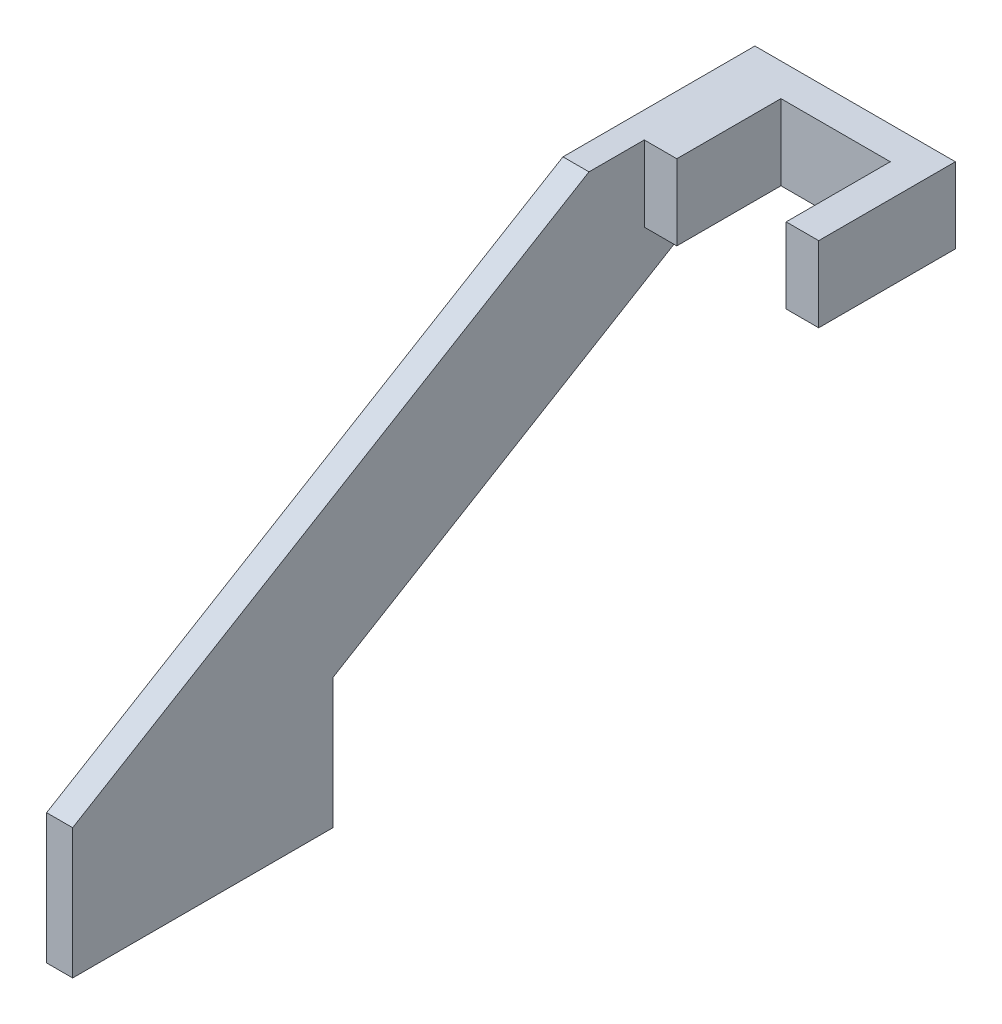
from build123d import *

# Parameters (mm, degrees)
BOSS_EXTRUDE1_DEPTH = 2.54
SKETCH2_W           = 3.175
SKETCH2_H           = 7.366
BOSS_EXTRUDE2_DEPTH = 3.175
SKETCH3_W           = 3.175
SKETCH3_H           = 7.366
BOSS_EXTRUDE4_DEPTH = 10.668
SKETCH4_W           = 13.335
SKETCH4_H           = 7.366
BOSS_EXTRUDE5_DEPTH = 3.175


with BuildPart() as part:
    # Sketch1 → Boss-Extrude1 (new body)
    with BuildSketch(Plane(origin=(0, 0, 0), x_dir=(0, 0, -1), z_dir=(1, 0, 0))):
        Polygon((-47.389657734, -29.937142578), (-21.989657734, -29.937142578), (-21.989657734, -17.237142578), (16.110342266, 5.622857422), (21.714787013, 5.622857422), (21.714787013, 12.988857422), (2.987008932, 12.988857422), (-47.389657734, -17.237142578), align=None)
    extrude(amount=BOSS_EXTRUDE1_DEPTH)

    # Sketch2 → Boss-Extrude2 (add)
    with BuildSketch(Plane(origin=(2.54, 0, 0), x_dir=(0, 0, -1), z_dir=(1, 0, 0))):
        Polygon((16.110342266, 5.622857422), (21.714787013, 5.622857422), (21.714787013, 12.988857422), (11.554787013, 12.988857422), (11.554787013, 5.622857422), align=None)
        with Locations((9.967287013, 9.305857422)):
            Rectangle(SKETCH2_W, SKETCH2_H)
    extrude(amount=BOSS_EXTRUDE2_DEPTH)

    # Sketch3 → Boss-Extrude4 (add)
    with BuildSketch(Plane(origin=(5.715, 0, 0), x_dir=(0, 0, -1), z_dir=(1, 0, 0))):
        with Locations((20.127287013, 9.305857422)):
            Rectangle(SKETCH3_W, SKETCH3_H)
    extrude(amount=BOSS_EXTRUDE4_DEPTH)

    # Sketch4 → Boss-Extrude5 (add)
    with BuildSketch(Plane(origin=(16.383, 0, 0), x_dir=(0, 0, -1), z_dir=(1, 0, 0))):
        with Locations((15.047287013, 9.305857422)):
            Rectangle(SKETCH4_W, SKETCH4_H)
    extrude(amount=BOSS_EXTRUDE5_DEPTH)


solid = part.part
